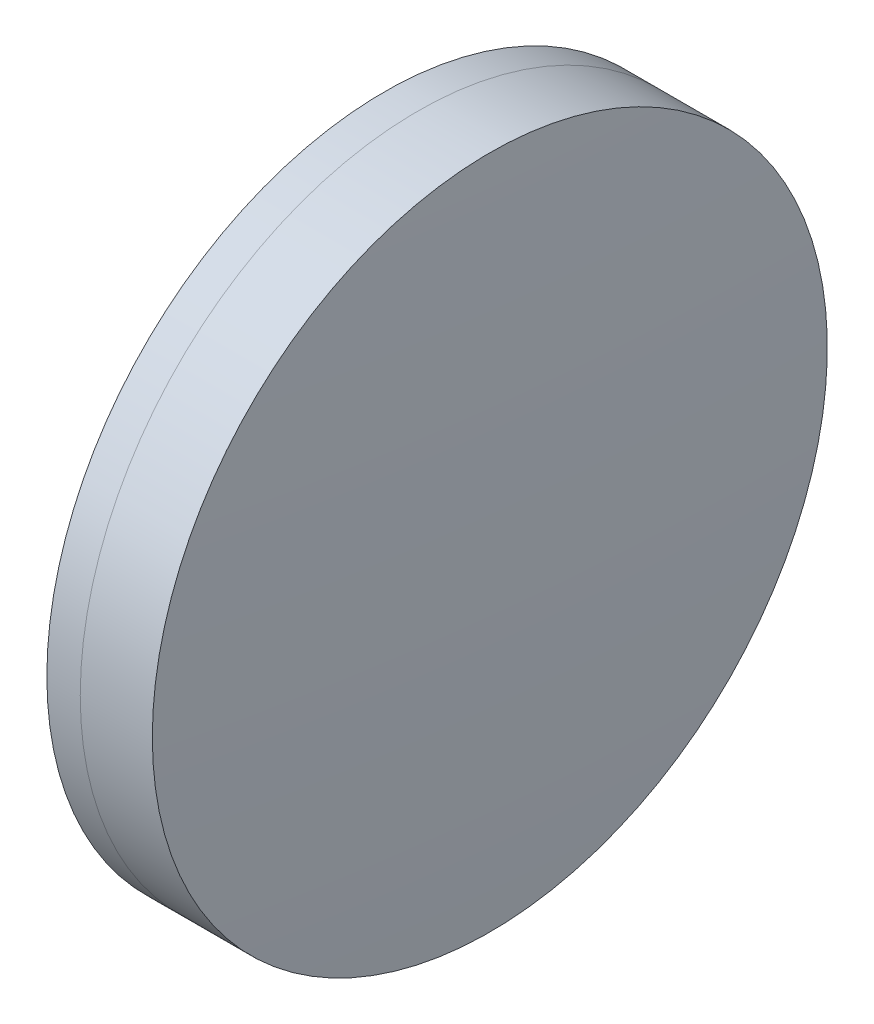
from build123d import *


with BuildPart() as part:
    # 草图1 one side → 旋转1 (revolve)
    with BuildSketch(Plane(origin=(0, 0, 0), x_dir=(1, 0, 0), z_dir=(0, 1, 0)), mode=Mode.PRIVATE) as revolve_1_sk:
        with BuildLine():
            ThreePointArc((300.92073089, 12.7), (300.00597863, 6.379260859), (299.700125938, 0))
            Line((299.700125938, 0), (303.700125938, 0))
            ThreePointArc((303.700125938, 0), (303.317921567, 6.395519469), (302.176749056, 12.7))
            Line((302.176749056, 12.7), (300.92073089, 12.7))
        make_face()
    revolve(revolve_1_sk.sketch.rotate(Axis((124.523309526, 0, 0), (1, 0, 0)), 180), axis=Axis((124.523309526, 0, 0), (1, 0, 0)))  # turned: the seam where the file's is


with BuildPart() as body_2:
    # 草图2 one side → 旋转3 (revolve)
    with BuildSketch(Plane(origin=(0, 0, 0), x_dir=(1, 0, 0), z_dir=(0, 1, 0)), mode=Mode.PRIVATE) as revolve_3_sk:
        with BuildLine():
            Line((304.889060903, 12.7), (302.176749056, 12.7))
            ThreePointArc((302.176749056, 12.7), (303.317921567, 6.395519469), (303.700125938, 0))
            Line((303.700125938, 0), (305.200125938, 0))
            ThreePointArc((305.200125938, 0), (305.122348019, 6.351904467), (304.889060903, 12.7))
        make_face()
    revolve(revolve_3_sk.sketch.rotate(Axis((-0.551919993, 0, 0), (1, 0, 0)), 180), axis=Axis((-0.551919993, 0, 0), (1, 0, 0)))  # turned: the seam where the file's is


solid = Compound([part.part, body_2.part])
